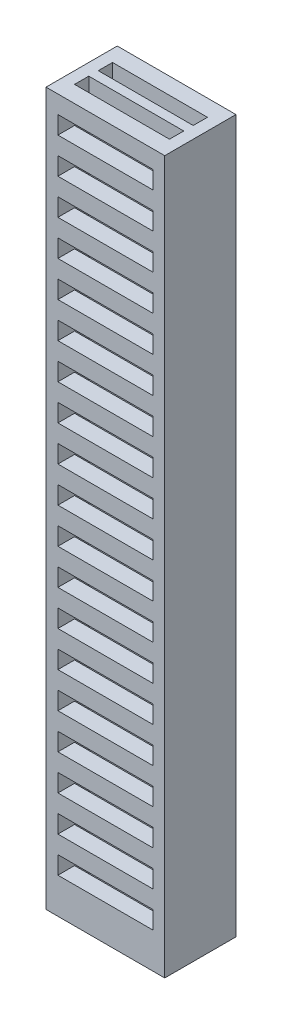
from build123d import *

# Parameters (mm, degrees)
SKETCH1_W                = 5
SKETCH1_H                = 3
BOSS_EXTRUDE1_DEPTH      = 15
CUT_EXTRUDE1_START       = -31
SKETCH2_W                = 4
SKETCH2_H                = 0.6
CUT_EXTRUDE1_DEPTH       = 32
SKETCH3_W                = 4
SKETCH3_H                = 0.75
CUT_EXTRUDE2_DEPTH       = 0.7
LPATTERN1_COUNT          = 19
LPATTERN1_PITCH          = 1.5
MIRROR2_COPY_1_SKETCH_W  = 4
MIRROR2_COPY_1_SKETCH_H  = 0.75
MIRROR2_COPY_1_DEPTH     = 0.7
MIRROR2_COPY_2_SKETCH_W  = 4
MIRROR2_COPY_2_SKETCH_H  = 0.75
MIRROR2_COPY_2_DEPTH     = 0.7
MIRROR2_COPY_3_SKETCH_W  = 4
MIRROR2_COPY_3_SKETCH_H  = 0.75
MIRROR2_COPY_3_DEPTH     = 0.7
MIRROR2_COPY_4_SKETCH_W  = 4
MIRROR2_COPY_4_SKETCH_H  = 0.75
MIRROR2_COPY_4_DEPTH     = 0.7
MIRROR2_COPY_5_SKETCH_W  = 4
MIRROR2_COPY_5_SKETCH_H  = 0.75
MIRROR2_COPY_5_DEPTH     = 0.7
MIRROR2_COPY_6_SKETCH_W  = 4
MIRROR2_COPY_6_SKETCH_H  = 0.75
MIRROR2_COPY_6_DEPTH     = 0.7
MIRROR2_COPY_7_SKETCH_W  = 4
MIRROR2_COPY_7_SKETCH_H  = 0.75
MIRROR2_COPY_7_DEPTH     = 0.7
MIRROR2_COPY_8_SKETCH_W  = 4
MIRROR2_COPY_8_SKETCH_H  = 0.75
MIRROR2_COPY_8_DEPTH     = 0.7
MIRROR2_COPY_9_SKETCH_W  = 4
MIRROR2_COPY_9_SKETCH_H  = 0.75
MIRROR2_COPY_9_DEPTH     = 0.7
MIRROR2_COPY_10_SKETCH_W = 4
MIRROR2_COPY_10_SKETCH_H = 0.75
MIRROR2_COPY_10_DEPTH    = 0.7
MIRROR2_COPY_11_SKETCH_W = 4
MIRROR2_COPY_11_SKETCH_H = 0.75
MIRROR2_COPY_11_DEPTH    = 0.7
MIRROR2_COPY_12_SKETCH_W = 4
MIRROR2_COPY_12_SKETCH_H = 0.75
MIRROR2_COPY_12_DEPTH    = 0.7
MIRROR2_COPY_13_SKETCH_W = 4
MIRROR2_COPY_13_SKETCH_H = 0.75
MIRROR2_COPY_13_DEPTH    = 0.7
MIRROR2_COPY_14_SKETCH_W = 4
MIRROR2_COPY_14_SKETCH_H = 0.75
MIRROR2_COPY_14_DEPTH    = 0.7
MIRROR2_COPY_15_SKETCH_W = 4
MIRROR2_COPY_15_SKETCH_H = 0.75
MIRROR2_COPY_15_DEPTH    = 0.7
MIRROR2_COPY_16_SKETCH_W = 4
MIRROR2_COPY_16_SKETCH_H = 0.75
MIRROR2_COPY_16_DEPTH    = 0.7
MIRROR2_COPY_17_SKETCH_W = 4
MIRROR2_COPY_17_SKETCH_H = 0.75
MIRROR2_COPY_17_DEPTH    = 0.7
MIRROR2_COPY_18_SKETCH_W = 4
MIRROR2_COPY_18_SKETCH_H = 0.75
MIRROR2_COPY_18_DEPTH    = 0.7


with BuildPart() as part:
    # Sketch1 → Boss-Extrude1 (new body, symmetric)
    with BuildSketch(Plane(origin=(0, 0, 0), x_dir=(1, 0, 0), z_dir=(0, 1, 0))):
        Rectangle(SKETCH1_W, SKETCH1_H)
    extrude(amount=BOSS_EXTRUDE1_DEPTH, both=True)

    # Sketch2 → Cut-Extrude1 (cut)
    with BuildSketch(Plane(origin=(0, 15, 0), x_dir=(1, 0, 0), z_dir=(0, 1, 0)).offset(CUT_EXTRUDE1_START)):
        with Locations((0, 0.5)):
            Rectangle(SKETCH2_W, SKETCH2_H)
    cut_extrude1 = extrude(amount=CUT_EXTRUDE1_DEPTH, mode=Mode.SUBTRACT)

    # Mirror1: Cut-Extrude1 across plane
    add(cut_extrude1.mirror(Plane.XY), mode=Mode.SUBTRACT)

    # Sketch3 → Cut-Extrude2 (cut)
    with BuildSketch(Plane.XY.offset(1.5)):
        with Locations((0, 13.875)):
            Rectangle(SKETCH3_W, SKETCH3_H)
    cut_extrude2 = extrude(amount=-CUT_EXTRUDE2_DEPTH, mode=Mode.SUBTRACT)

    # LPattern1: Cut-Extrude2 ×19
    with Locations(*[(0, -i * LPATTERN1_PITCH, 0) for i in range(1, LPATTERN1_COUNT)]):
        add(cut_extrude2, mode=Mode.SUBTRACT)

    # Mirror2: Cut-Extrude2 across plane
    add(cut_extrude2.mirror(Plane.XY), mode=Mode.SUBTRACT)

    # Mirror2 copy 1 sketch → Mirror2 copy 1 (cut)
    with BuildSketch(Plane(origin=(0, -1.5, -1.5), x_dir=(1, 0, 0), z_dir=(0, 0, -1))):
        with Locations((0, -13.875)):
            Rectangle(MIRROR2_COPY_1_SKETCH_W, MIRROR2_COPY_1_SKETCH_H)
    extrude(amount=-MIRROR2_COPY_1_DEPTH, mode=Mode.SUBTRACT)

    # Mirror2 copy 2 sketch → Mirror2 copy 2 (cut)
    with BuildSketch(Plane(origin=(0, -3, -1.5), x_dir=(1, 0, 0), z_dir=(0, 0, -1))):
        with Locations((0, -13.875)):
            Rectangle(MIRROR2_COPY_2_SKETCH_W, MIRROR2_COPY_2_SKETCH_H)
    extrude(amount=-MIRROR2_COPY_2_DEPTH, mode=Mode.SUBTRACT)

    # Mirror2 copy 3 sketch → Mirror2 copy 3 (cut)
    with BuildSketch(Plane(origin=(0, -4.5, -1.5), x_dir=(1, 0, 0), z_dir=(0, 0, -1))):
        with Locations((0, -13.875)):
            Rectangle(MIRROR2_COPY_3_SKETCH_W, MIRROR2_COPY_3_SKETCH_H)
    extrude(amount=-MIRROR2_COPY_3_DEPTH, mode=Mode.SUBTRACT)

    # Mirror2 copy 4 sketch → Mirror2 copy 4 (cut)
    with BuildSketch(Plane(origin=(0, -6, -1.5), x_dir=(1, 0, 0), z_dir=(0, 0, -1))):
        with Locations((0, -13.875)):
            Rectangle(MIRROR2_COPY_4_SKETCH_W, MIRROR2_COPY_4_SKETCH_H)
    extrude(amount=-MIRROR2_COPY_4_DEPTH, mode=Mode.SUBTRACT)

    # Mirror2 copy 5 sketch → Mirror2 copy 5 (cut)
    with BuildSketch(Plane(origin=(0, -7.5, -1.5), x_dir=(1, 0, 0), z_dir=(0, 0, -1))):
        with Locations((0, -13.875)):
            Rectangle(MIRROR2_COPY_5_SKETCH_W, MIRROR2_COPY_5_SKETCH_H)
    extrude(amount=-MIRROR2_COPY_5_DEPTH, mode=Mode.SUBTRACT)

    # Mirror2 copy 6 sketch → Mirror2 copy 6 (cut)
    with BuildSketch(Plane(origin=(0, -9, -1.5), x_dir=(1, 0, 0), z_dir=(0, 0, -1))):
        with Locations((0, -13.875)):
            Rectangle(MIRROR2_COPY_6_SKETCH_W, MIRROR2_COPY_6_SKETCH_H)
    extrude(amount=-MIRROR2_COPY_6_DEPTH, mode=Mode.SUBTRACT)

    # Mirror2 copy 7 sketch → Mirror2 copy 7 (cut)
    with BuildSketch(Plane(origin=(0, -10.5, -1.5), x_dir=(1, 0, 0), z_dir=(0, 0, -1))):
        with Locations((0, -13.875)):
            Rectangle(MIRROR2_COPY_7_SKETCH_W, MIRROR2_COPY_7_SKETCH_H)
    extrude(amount=-MIRROR2_COPY_7_DEPTH, mode=Mode.SUBTRACT)

    # Mirror2 copy 8 sketch → Mirror2 copy 8 (cut)
    with BuildSketch(Plane(origin=(0, -12, -1.5), x_dir=(1, 0, 0), z_dir=(0, 0, -1))):
        with Locations((0, -13.875)):
            Rectangle(MIRROR2_COPY_8_SKETCH_W, MIRROR2_COPY_8_SKETCH_H)
    extrude(amount=-MIRROR2_COPY_8_DEPTH, mode=Mode.SUBTRACT)

    # Mirror2 copy 9 sketch → Mirror2 copy 9 (cut)
    with BuildSketch(Plane(origin=(0, -13.5, -1.5), x_dir=(1, 0, 0), z_dir=(0, 0, -1))):
        with Locations((0, -13.875)):
            Rectangle(MIRROR2_COPY_9_SKETCH_W, MIRROR2_COPY_9_SKETCH_H)
    extrude(amount=-MIRROR2_COPY_9_DEPTH, mode=Mode.SUBTRACT)

    # Mirror2 copy 10 sketch → Mirror2 copy 10 (cut)
    with BuildSketch(Plane(origin=(0, -15, -1.5), x_dir=(1, 0, 0), z_dir=(0, 0, -1))):
        with Locations((0, -13.875)):
            Rectangle(MIRROR2_COPY_10_SKETCH_W, MIRROR2_COPY_10_SKETCH_H)
    extrude(amount=-MIRROR2_COPY_10_DEPTH, mode=Mode.SUBTRACT)

    # Mirror2 copy 11 sketch → Mirror2 copy 11 (cut)
    with BuildSketch(Plane(origin=(0, -16.5, -1.5), x_dir=(1, 0, 0), z_dir=(0, 0, -1))):
        with Locations((0, -13.875)):
            Rectangle(MIRROR2_COPY_11_SKETCH_W, MIRROR2_COPY_11_SKETCH_H)
    extrude(amount=-MIRROR2_COPY_11_DEPTH, mode=Mode.SUBTRACT)

    # Mirror2 copy 12 sketch → Mirror2 copy 12 (cut)
    with BuildSketch(Plane(origin=(0, -18, -1.5), x_dir=(1, 0, 0), z_dir=(0, 0, -1))):
        with Locations((0, -13.875)):
            Rectangle(MIRROR2_COPY_12_SKETCH_W, MIRROR2_COPY_12_SKETCH_H)
    extrude(amount=-MIRROR2_COPY_12_DEPTH, mode=Mode.SUBTRACT)

    # Mirror2 copy 13 sketch → Mirror2 copy 13 (cut)
    with BuildSketch(Plane(origin=(0, -19.5, -1.5), x_dir=(1, 0, 0), z_dir=(0, 0, -1))):
        with Locations((0, -13.875)):
            Rectangle(MIRROR2_COPY_13_SKETCH_W, MIRROR2_COPY_13_SKETCH_H)
    extrude(amount=-MIRROR2_COPY_13_DEPTH, mode=Mode.SUBTRACT)

    # Mirror2 copy 14 sketch → Mirror2 copy 14 (cut)
    with BuildSketch(Plane(origin=(0, -21, -1.5), x_dir=(1, 0, 0), z_dir=(0, 0, -1))):
        with Locations((0, -13.875)):
            Rectangle(MIRROR2_COPY_14_SKETCH_W, MIRROR2_COPY_14_SKETCH_H)
    extrude(amount=-MIRROR2_COPY_14_DEPTH, mode=Mode.SUBTRACT)

    # Mirror2 copy 15 sketch → Mirror2 copy 15 (cut)
    with BuildSketch(Plane(origin=(0, -22.5, -1.5), x_dir=(1, 0, 0), z_dir=(0, 0, -1))):
        with Locations((0, -13.875)):
            Rectangle(MIRROR2_COPY_15_SKETCH_W, MIRROR2_COPY_15_SKETCH_H)
    extrude(amount=-MIRROR2_COPY_15_DEPTH, mode=Mode.SUBTRACT)

    # Mirror2 copy 16 sketch → Mirror2 copy 16 (cut)
    with BuildSketch(Plane(origin=(0, -24, -1.5), x_dir=(1, 0, 0), z_dir=(0, 0, -1))):
        with Locations((0, -13.875)):
            Rectangle(MIRROR2_COPY_16_SKETCH_W, MIRROR2_COPY_16_SKETCH_H)
    extrude(amount=-MIRROR2_COPY_16_DEPTH, mode=Mode.SUBTRACT)

    # Mirror2 copy 17 sketch → Mirror2 copy 17 (cut)
    with BuildSketch(Plane(origin=(0, -25.5, -1.5), x_dir=(1, 0, 0), z_dir=(0, 0, -1))):
        with Locations((0, -13.875)):
            Rectangle(MIRROR2_COPY_17_SKETCH_W, MIRROR2_COPY_17_SKETCH_H)
    extrude(amount=-MIRROR2_COPY_17_DEPTH, mode=Mode.SUBTRACT)

    # Mirror2 copy 18 sketch → Mirror2 copy 18 (cut)
    with BuildSketch(Plane(origin=(0, -27, -1.5), x_dir=(1, 0, 0), z_dir=(0, 0, -1))):
        with Locations((0, -13.875)):
            Rectangle(MIRROR2_COPY_18_SKETCH_W, MIRROR2_COPY_18_SKETCH_H)
    extrude(amount=-MIRROR2_COPY_18_DEPTH, mode=Mode.SUBTRACT)


solid = part.part
